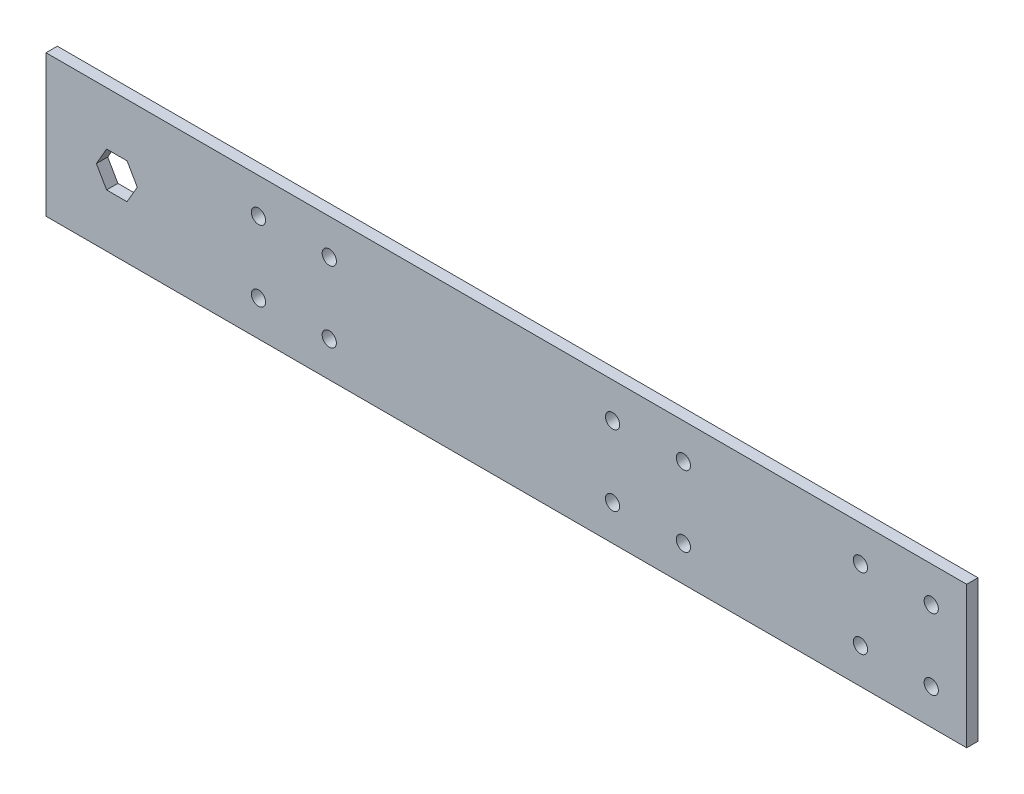
from build123d import *

# Parameters (mm, degrees)
SKETCH1_W                          = 330.2
SKETCH1_H                          = 50.8
BASE_DEPTH                         = 4.064
F_10_CLEARANCE_HOLE_BASKET_MOUNT_D = 5.1054
PIVOT_HOLE_DEPTH                   = 5.064
F_10_CLEARANCE_HOLE1_D             = 5.1054


with BuildPart() as part:
    # Sketch1 → base (new body)
    with BuildSketch(Plane.XY):
        with Locations((165.1, 25.4)):
            Rectangle(SKETCH1_W, SKETCH1_H)
    extrude(amount=BASE_DEPTH)

    # #10 Clearance Hole - basket mount (through all)
    with Locations(Plane.XY.offset(4.064)):
        with Locations((203.2, 12.7), (228.6, 38.1), (203.2, 38.1), (228.6, 12.7), (76.2, 38.1), (101.6, 12.7), (76.2, 12.7), (101.6, 38.1)):
            Hole(F_10_CLEARANCE_HOLE_BASKET_MOUNT_D / 2)

    # Sketch7 → pivot hole (cut, through all)
    with BuildSketch(Plane.XY.offset(4.064)):
        Polygon((21.733825791, 31.75), (18.067651581, 25.4), (21.733825791, 19.05), (29.066174209, 19.05), (32.732348419, 25.4), (29.066174209, 31.75), align=None)
    extrude(amount=-PIVOT_HOLE_DEPTH, mode=Mode.SUBTRACT)

    # #10 Clearance Hole1 (through all)
    with Locations(Plane.XY.offset(4.064)):
        with Locations((317.5, 38.1), (292.1, 12.7), (317.5, 12.7), (292.1, 38.1)):
            Hole(F_10_CLEARANCE_HOLE1_D / 2)


solid = part.part
